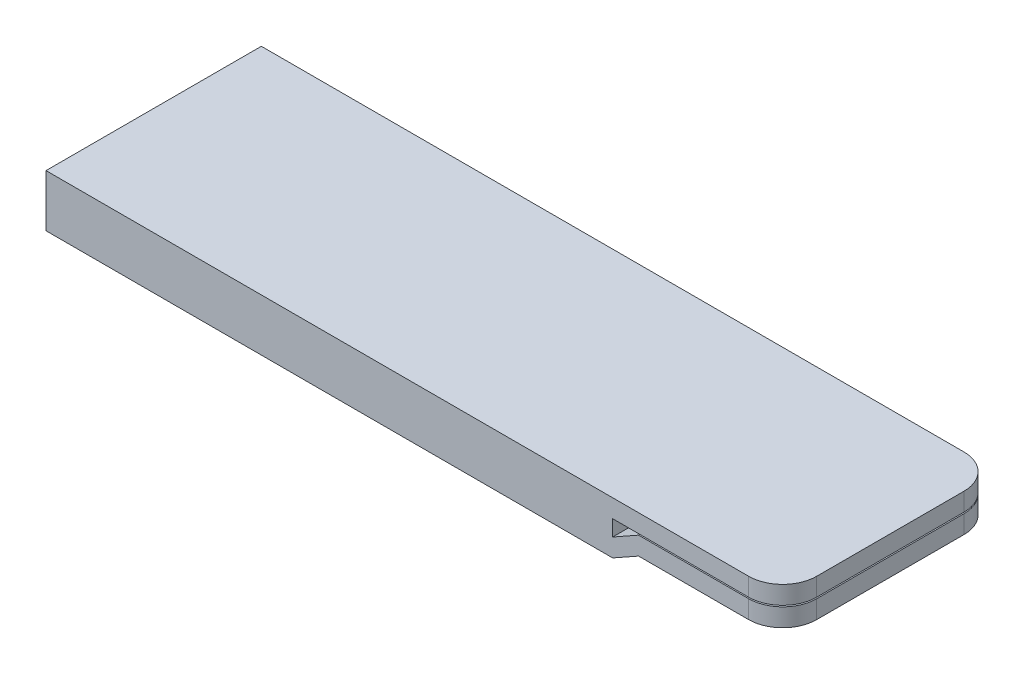
from build123d import *

# Parameters (mm, degrees)
BOSS_EXTRUDE1_DEPTH = 9.5
FILLET1_R           = 3


with BuildPart() as part:
    # Sketch1 → Boss-Extrude1 (new body, symmetric)
    with BuildSketch(Plane.XY):
        Polygon((-32.5, 2.3), (32.5, 2.3), (32.5, 0.7), (17.5, 0.7), (17.5, -0.7), (19.784478645, 0.584636857), (32.5, 0.584636857), (32.5, -1.015363143), (19.784478645, -1.015363143), (17.5, -2.3), (-32.5, -2.3), align=None)
    extrude(amount=BOSS_EXTRUDE1_DEPTH, both=True)

    # Fillet1
    fillet1_edges = [part.edges().sort_by_distance(p)[0] for p in [
        (32.5, 1.5, -9.5),
        (32.5, -0.215363143, -9.5),
        (32.5, 1.5, 9.5),
        (32.5, -0.215363143, 9.5),
    ]]
    fillet(fillet1_edges, radius=FILLET1_R)


solid = part.part
